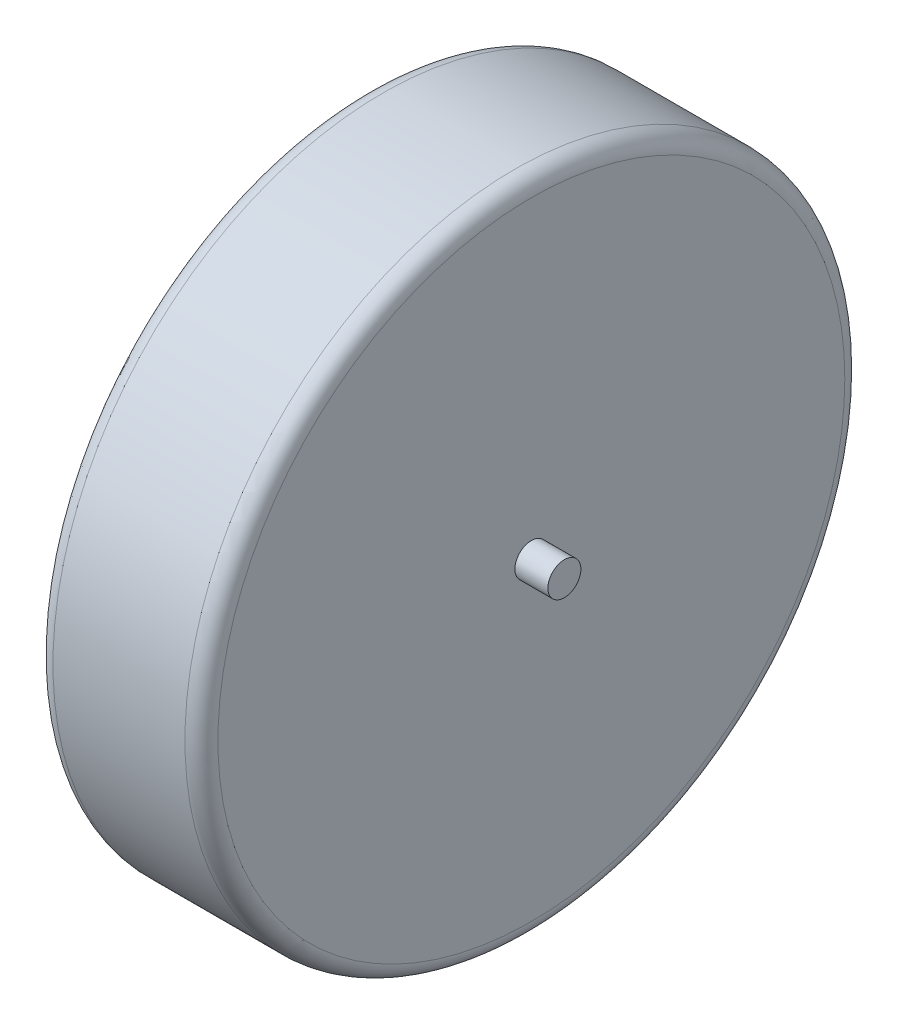
from build123d import *

# Parameters (mm, degrees)
SKETCH1_R           = 20
BOSS_EXTRUDE1_DEPTH = 10
SKETCH2_R           = 1
BOSS_EXTRUDE2_DEPTH = 2
SKETCH3_R           = 1
BOSS_EXTRUDE3_DEPTH = 2
FILLET2_R           = 1


with BuildPart() as part:
    # Sketch1 → Boss-Extrude1 (new body)
    with BuildSketch(Plane(origin=(0, 0, 0), x_dir=(0, 0, -1), z_dir=(1, 0, 0))):
        Circle(SKETCH1_R)
    extrude(amount=BOSS_EXTRUDE1_DEPTH)

    # Sketch2 → Boss-Extrude2 (add)
    with BuildSketch(Plane(origin=(10, 0, 0), x_dir=(0, 0, -1), z_dir=(1, 0, 0))):
        Circle(SKETCH2_R)
    extrude(amount=BOSS_EXTRUDE2_DEPTH)

    # Sketch3 → Boss-Extrude3 (add)
    with BuildSketch(Plane.ZY):
        Circle(SKETCH3_R)
    extrude(amount=BOSS_EXTRUDE3_DEPTH)

    # Fillet2
    fillet2_edges = [part.edges().sort_by_distance(p)[0] for p in [
        (0, 0, 20),
        (10, 0, 20),
    ]]
    fillet(fillet2_edges, radius=FILLET2_R)


solid = part.part
